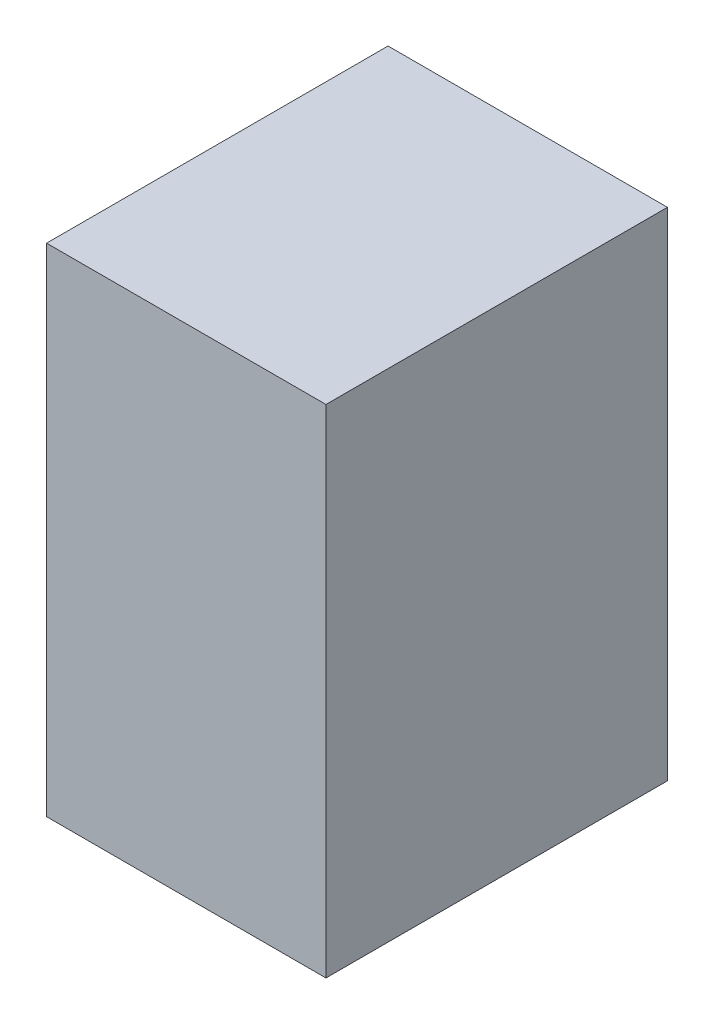
from build123d import *

# Parameters (mm, degrees)
SKETCH_1_W      = 450
SKETCH_1_H      = 550
EXTRUDE_1_DEPTH = 800


with BuildPart() as part:
    # Эскиз1 → Бобышка-Вытянуть1 (new body)
    with BuildSketch(Plane(origin=(0, 0, 0), x_dir=(1, 0, 0), z_dir=(0, 1, 0))):
        with Locations((225, 275)):
            Rectangle(SKETCH_1_W, SKETCH_1_H)
    extrude(amount=EXTRUDE_1_DEPTH)


solid = part.part
